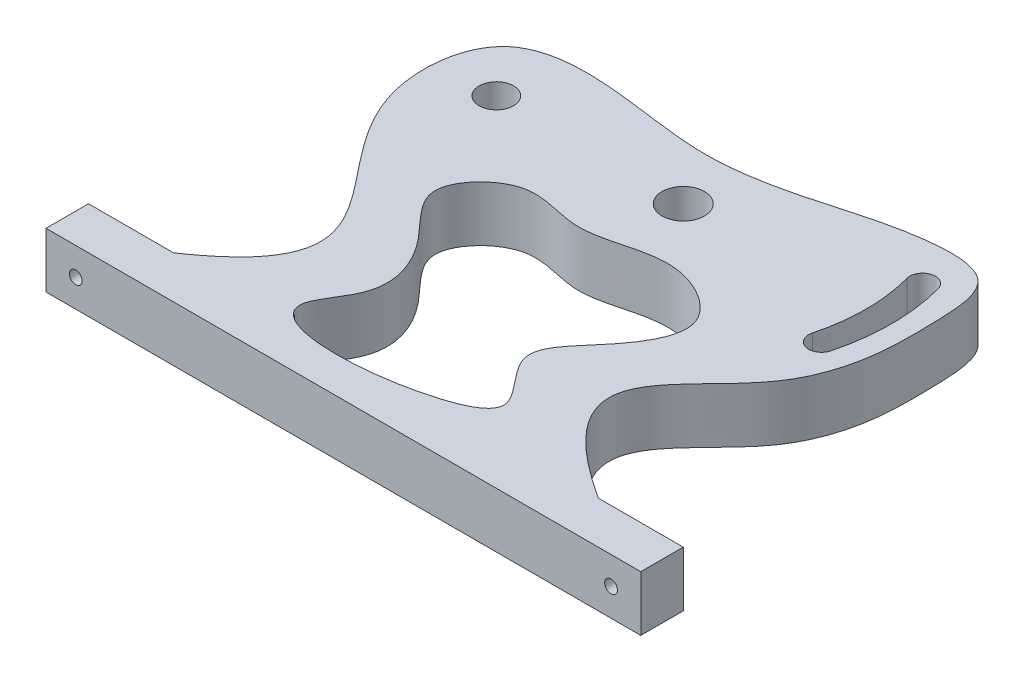
from build123d import *

# Parameters (mm, degrees)
SKETCH_1_R          = 5
SKETCH_1_R_2        = 4.064442724
EXTRUDE_1_DEPTH     = 13
SKETCH_2_R          = 1.5
CUT_EXTRUDE_1_DEPTH = 137.780182209


with BuildPart() as part:
    # Эскиз1 → Бобышка-Вытянуть1 (new body)
    with BuildSketch(Plane(origin=(0, 0, 0), x_dir=(1, 0, 0), z_dir=(0, 1, 0))):
        with BuildLine():
            Line((-39.172537319, -43.944715555), (100.827462681, -43.944715555))
            Line((100.827462681, -43.944715555), (100.827462681, -33.944715555))
            Line((100.827462681, -33.944715555), (80.827462681, -33.944715555))
            add(Edge.make_bspline(
                [(-19.172537319, -33.944715555), (15.431052623, -10.540045689), (-31.247357789, 4.121631603), (-26.204990769, 51.926699145), (2.027145984, 51.722466482), (22.556738039, 47.250579483), (45.329079993, 51.633229941), (61.898452862, 57.424745052), (83.888025827, 58.40728552), (84.680304188, 39.819458189), (84.717824209, 26.068709047), (75.220512051, -1.517975589), (44.444985829, -10.441068178), (80.827462681, -33.944715555)],
                knots=[0, 0, 0, 0, 0.233238497, 0.310065537, 0.386429131, 0.471524665, 0.535672012, 0.612570576, 0.667146875, 0.712511569, 0.77025153, 0.815618744, 1, 1, 1, 1], degree=3))
            Line((-19.172537319, -33.944715555), (-39.172537319, -33.944715555))
            Line((-39.172537319, -33.944715555), (-39.172537319, -43.944715555))
        make_face()
        with Locations(Location((30.827462681, 36.055284445, 0), (0, 0, 90))):
            Circle(SKETCH_1_R, mode=Mode.SUBTRACT)
        with Locations(Location((-13.172537319, 36.055284445, 0), (0, 0, 90))):
            Circle(SKETCH_1_R_2, mode=Mode.SUBTRACT)
        with BuildLine():
            add(Edge.make_bspline(
                [(6.518838364, -28.61141188), (7.199151809, -26.038769824), (14.938194381, -17.109547271), (8.926678395, -2.4298395), (-5.628384386, 8.939314794), (8.287836876, 23.832813655), (24.984024358, 15.834363618), (40.810971074, 26.017213268), (61.287995774, 13.792502195), (51.320489704, -1.648432213), (38.702399688, -13.871478692), (56.458102471, -26.892153214), (32.23735813, -37.045816623), (4.383128146, -36.687715476), (6.518838364, -28.61141188)],
                knots=[0, 0, 0, 0, 0.053473242, 0.141845405, 0.214492711, 0.285603418, 0.356448288, 0.46456582, 0.54200973, 0.627309954, 0.694064883, 0.765175347, 0.832131277, 1, 1, 1, 1], degree=3))
        make_face(mode=Mode.SUBTRACT)
        with BuildLine():
            ThreePointArc((72.362273212, 24.926065505), (73.827462681, 36.055284445), (72.362273212, 47.184503384))
            ThreePointArc((72.362273212, 47.184503384), (74.483593555, 50.858737998), (78.157828169, 48.737417655))
            ThreePointArc((78.157828169, 48.737417655), (79.827462681, 36.055284445), (78.157828169, 23.373151235))
            ThreePointArc((78.157828169, 23.373151235), (74.483593555, 21.251830891), (72.362273212, 24.926065505))
        make_face(mode=Mode.SUBTRACT)
    extrude(amount=EXTRUDE_1_DEPTH)

    # Эскиз2 → Вырез-Вытянуть1 (cut, through all)
    with BuildSketch(Plane(origin=(0, 0, 33.944715555), x_dir=(-1, 0, 0), z_dir=(0, 0, -1))):
        with Locations((-93.827462681, 6.5)):
            Circle(SKETCH_2_R)
        with Locations((32.172537319, 6.5)):
            Circle(SKETCH_2_R)
    extrude(amount=-CUT_EXTRUDE_1_DEPTH, mode=Mode.SUBTRACT)


solid = part.part
